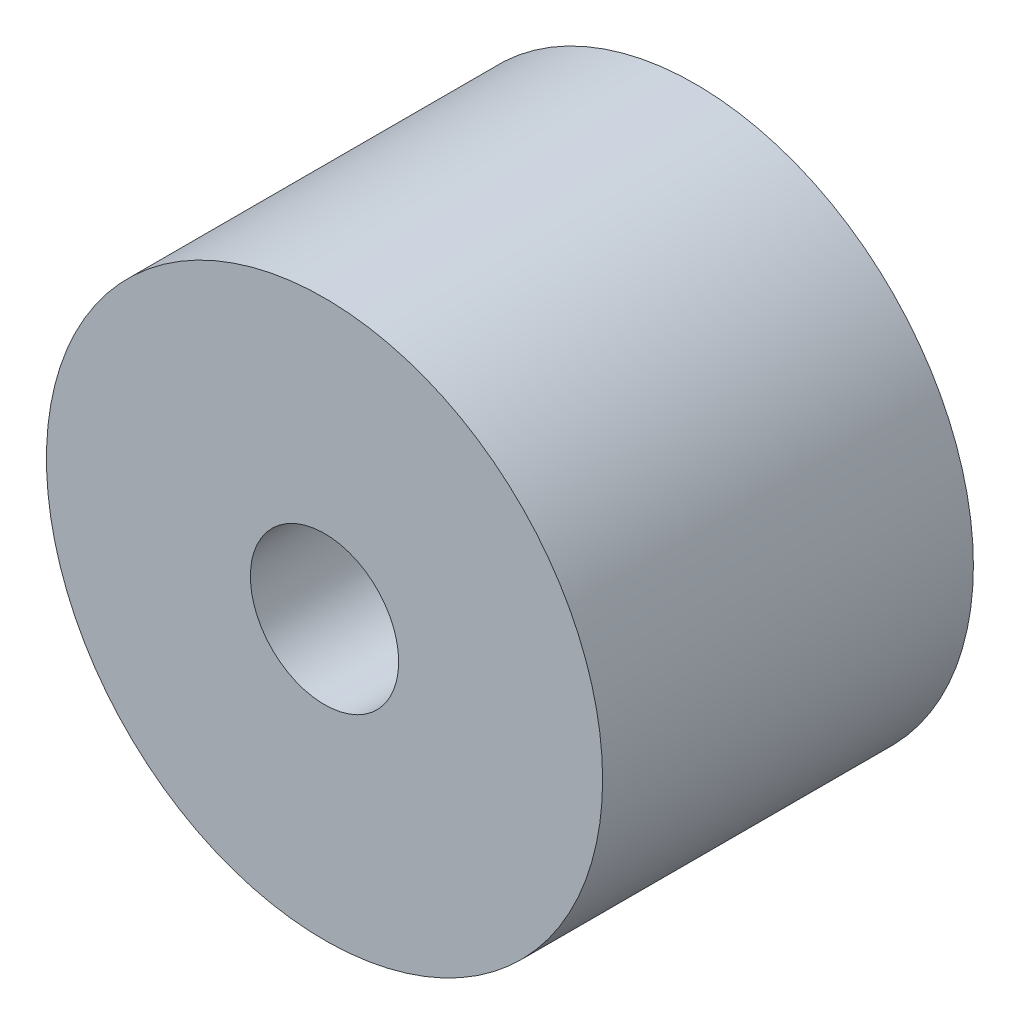
from build123d import *

# Parameters (mm, degrees)
SKETCH_1_R      = 15
SKETCH_1_R_2    = 4
EXTRUDE_1_DEPTH = 10


with BuildPart() as part:
    # 草图1 → 凸台-拉伸1 (new body, symmetric)
    with BuildSketch(Plane.XY):
        Circle(SKETCH_1_R)
        Circle(SKETCH_1_R_2, mode=Mode.SUBTRACT)
    extrude(amount=EXTRUDE_1_DEPTH, both=True)


solid = part.part
